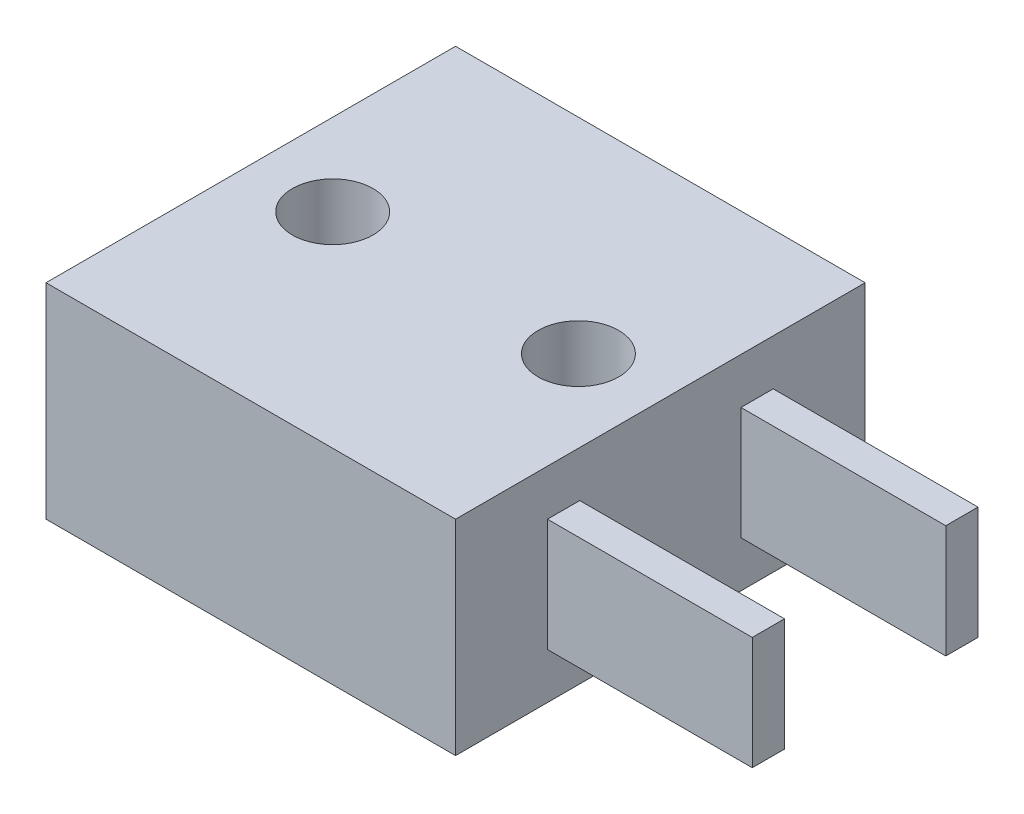
from build123d import *

# Parameters (mm, degrees)
SKETCH1_W           = 12.7
SKETCH1_H           = 12.7
SKETCH1_R           = 1.25
BOSS_EXTRUDE1_DEPTH = 3.175
SKETCH2_W           = 6.35
SKETCH2_H           = 1
BOSS_EXTRUDE2_DEPTH = 1.75


with BuildPart() as part:
    # Sketch1 → Boss-Extrude1 (new body, symmetric)
    with BuildSketch(Plane(origin=(0, 0, 0), x_dir=(1, 0, 0), z_dir=(0, 1, 0))):
        Rectangle(SKETCH1_W, SKETCH1_H)
        with Locations((-3.81, 0)):
            Circle(SKETCH1_R, mode=Mode.SUBTRACT)
        with Locations((3.81, 0)):
            Circle(SKETCH1_R, mode=Mode.SUBTRACT)
    extrude(amount=BOSS_EXTRUDE1_DEPTH, both=True)

    # Sketch2 → Boss-Extrude2 (add, symmetric)
    with BuildSketch(Plane(origin=(0, 0, 0), x_dir=(1, 0, 0), z_dir=(0, 1, 0))):
        with Locations((9.525, 3)):
            Rectangle(SKETCH2_W, SKETCH2_H)
        with Locations((9.525, -3)):
            Rectangle(SKETCH2_W, SKETCH2_H)
    extrude(amount=BOSS_EXTRUDE2_DEPTH, both=True)


solid = part.part
